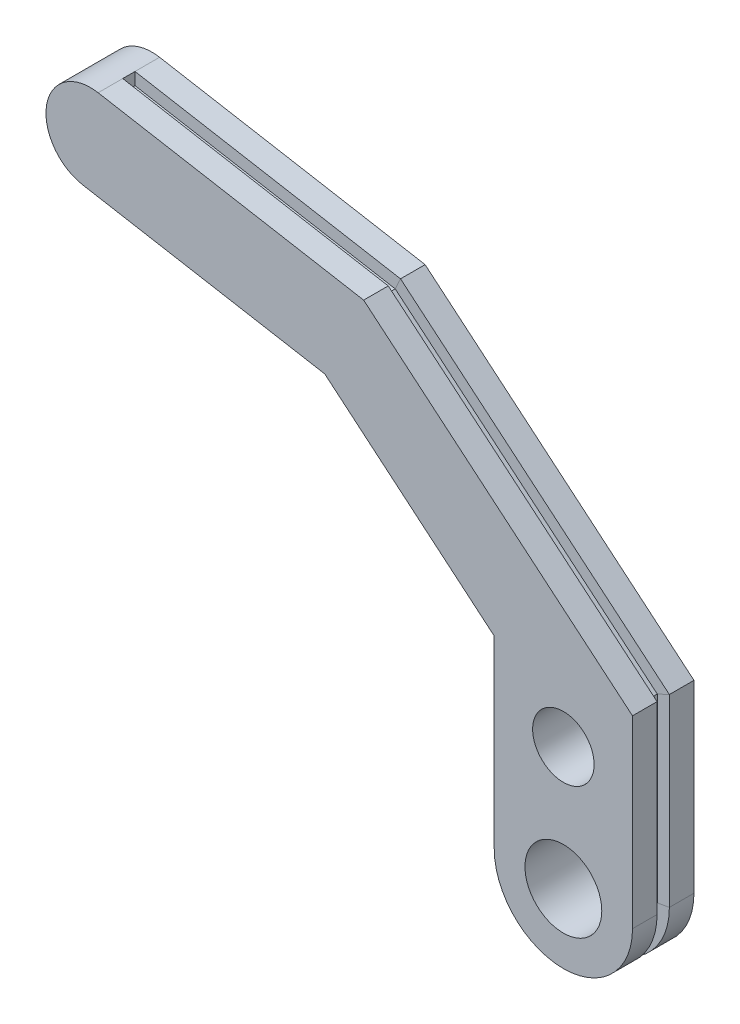
from build123d import *

# Parameters (mm, degrees)
SKETCH3_R           = 3.96875
SKETCH3_R_2         = 3.175
BOSS_EXTRUDE1_DEPTH = 6.35
SKETCH4_W           = 1.27
SKETCH4_H           = 1.27


with BuildPart() as part:
    # Sketch3 → Boss-Extrude1 (new body)
    with BuildSketch(Plane.XY):
        with BuildLine():
            Line((7.14375, 19.05), (7.14375, 0))
            ThreePointArc((7.14375, 0), (0, -7.14375), (-7.14375, 0))
            Line((-7.14375, 0), (-7.14375, 19.05))
            Line((-7.14375, 19.05), (-24.65552597, 33.744124757))
            Line((-24.65552597, 33.744124757), (-49.669642896, 38.15478847))
            ThreePointArc((-49.669642896, 38.15478847), (-53.394417896, 43.474318461), (-48.074887905, 47.199093461))
            Line((-48.074887905, 47.199093461), (-20.63735676, 42.361116436))
            Line((-20.63735676, 42.361116436), (7.14375, 19.05))
        make_face()
        Circle(SKETCH3_R, mode=Mode.SUBTRACT)
        with Locations((0, 12.7)):
            Circle(SKETCH3_R_2, mode=Mode.SUBTRACT)
    extrude(amount=BOSS_EXTRUDE1_DEPTH)

    # Cut-Sweep1: sweep along a path in Sketch6
    with BuildLine(Plane(origin=(0, 0, 0), x_dir=(-1, 0, 0), z_dir=(0, 0, -1))) as cut_sweep1_path:
        Line((48.074887905, 47.199093461), (20.63735676, 42.361116436))
        Line((20.63735676, 42.361116436), (-7.14375, 19.05))
        Line((-7.14375, 19.05), (-7.14375, 0))
        ThreePointArc((-7.14375, 0), (0, -7.14375), (7.14375, 0))
    # Sketch4 → Cut-Sweep1 (sweep, cut)
    with BuildSketch(Plane(origin=(-48.074887905, 0, 0), x_dir=(0, 0, -1), z_dir=(1, 0, 0))):
        with Locations((-3.175, 46.564093461)):
            Rectangle(SKETCH4_W, SKETCH4_H)
    sweep(path=cut_sweep1_path.line, transition=Transition.RIGHT, mode=Mode.SUBTRACT)


solid = part.part
